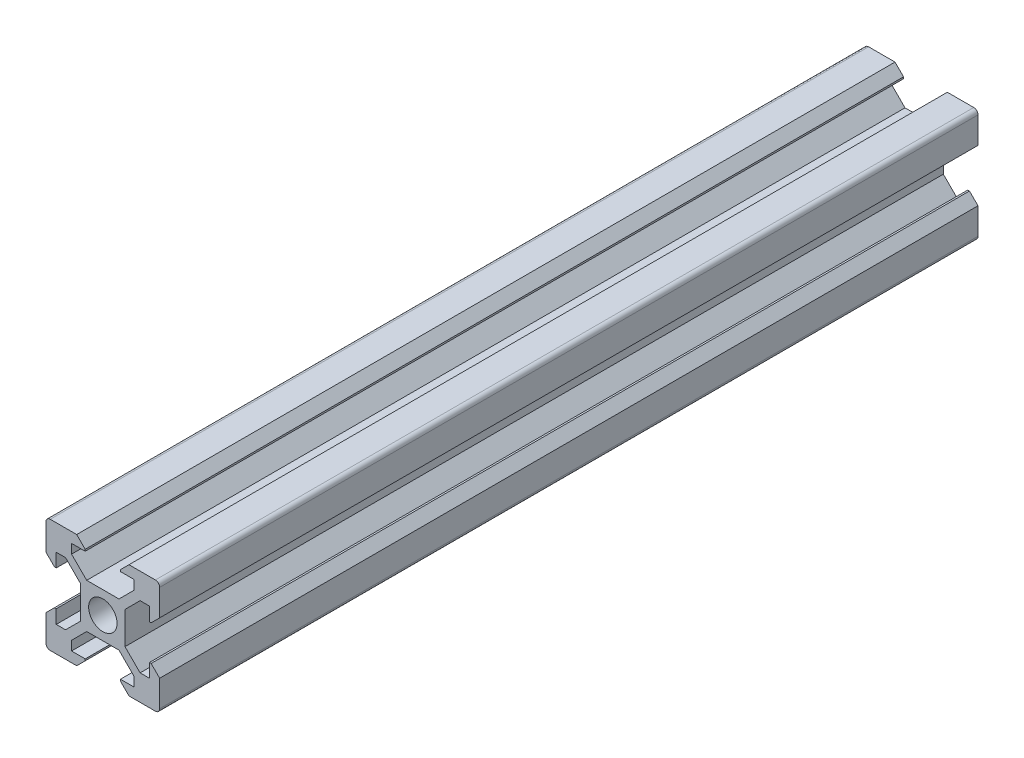
from build123d import *

# Parameters (mm, degrees)
CROQUIS1_R              = 2.5
SALIENTE_EXTRUIR1_DEPTH = 144


with BuildPart() as part:
    # Croquis1 → Saliente-Extruir1 (new body)
    with BuildSketch(Plane.XY):
        with BuildLine():
            Line((-4.6, 10), (-3.1, 8.5))
            Line((-3.1, 8.5), (-3.1, 8.2))
            Line((-3.1, 8.2), (-5.5, 8.2))
            Line((-5.5, 8.2), (-5.5, 6.560660172))
            Line((-5.5, 6.560660172), (-2.84, 3.900660172))
            Line((-2.84, 3.900660172), (0, 3.900660172))
            Line((0, 3.900660172), (2.84, 3.900660172))
            Line((2.84, 3.900660172), (5.5, 6.560660172))
            Line((5.5, 6.560660172), (5.5, 8.2))
            Line((5.5, 8.2), (3.1, 8.2))
            Line((3.1, 8.2), (3.1, 8.5))
            Line((3.1, 8.5), (4.6, 10))
            Line((4.6, 10), (9.25, 10))
            ThreePointArc((9.25, 10), (9.780330086, 9.780330086), (10, 9.25))
            Line((10, 9.25), (10, 4.6))
            Line((10, 4.6), (8.5, 3.1))
            Line((8.5, 3.1), (8.2, 3.1))
            Line((8.2, 3.1), (8.2, 5.5))
            Line((8.2, 5.5), (6.560660172, 5.5))
            Line((6.560660172, 5.5), (3.900660172, 2.84))
            Line((3.900660172, 2.84), (3.900660172, 0))
            Line((3.900660172, 0), (3.900660172, -2.84))
            Line((3.900660172, -2.84), (6.560660172, -5.5))
            Line((6.560660172, -5.5), (8.2, -5.5))
            Line((8.2, -5.5), (8.2, -3.1))
            Line((8.2, -3.1), (8.5, -3.1))
            Line((8.5, -3.1), (10, -4.6))
            Line((10, -4.6), (10, -9.25))
            ThreePointArc((10, -9.25), (9.780330086, -9.780330086), (9.25, -10))
            Line((9.25, -10), (4.6, -10))
            Line((4.6, -10), (3.1, -8.5))
            Line((3.1, -8.5), (3.1, -8.2))
            Line((3.1, -8.2), (5.5, -8.2))
            Line((5.5, -8.2), (5.5, -6.560660172))
            Line((5.5, -6.560660172), (2.84, -3.900660172))
            Line((2.84, -3.900660172), (0, -3.900660172))
            Line((0, -3.900660172), (-2.84, -3.900660172))
            Line((-2.84, -3.900660172), (-5.5, -6.560660172))
            Line((-5.5, -6.560660172), (-5.5, -8.2))
            Line((-5.5, -8.2), (-3.1, -8.2))
            Line((-3.1, -8.2), (-3.1, -8.5))
            Line((-3.1, -8.5), (-4.6, -10))
            Line((-4.6, -10), (-9.25, -10))
            ThreePointArc((-9.25, -10), (-9.780330086, -9.780330086), (-10, -9.25))
            Line((-10, -9.25), (-10, -4.6))
            Line((-10, -4.6), (-8.5, -3.1))
            Line((-8.5, -3.1), (-8.2, -3.1))
            Line((-8.2, -3.1), (-8.2, -5.5))
            Line((-8.2, -5.5), (-6.560660172, -5.5))
            Line((-6.560660172, -5.5), (-3.900660172, -2.84))
            Line((-3.900660172, -2.84), (-3.900660172, 0))
            Line((-3.900660172, 0), (-3.900660172, 2.84))
            Line((-3.900660172, 2.84), (-6.560660172, 5.5))
            Line((-6.560660172, 5.5), (-8.2, 5.5))
            Line((-8.2, 5.5), (-8.2, 3.1))
            Line((-8.2, 3.1), (-8.5, 3.1))
            Line((-8.5, 3.1), (-10, 4.6))
            Line((-10, 4.6), (-10, 9.25))
            ThreePointArc((-10, 9.25), (-9.780330086, 9.780330086), (-9.25, 10))
            Line((-9.25, 10), (-4.6, 10))
        make_face()
        Circle(CROQUIS1_R, mode=Mode.SUBTRACT)
    extrude(amount=SALIENTE_EXTRUIR1_DEPTH)


solid = part.part
